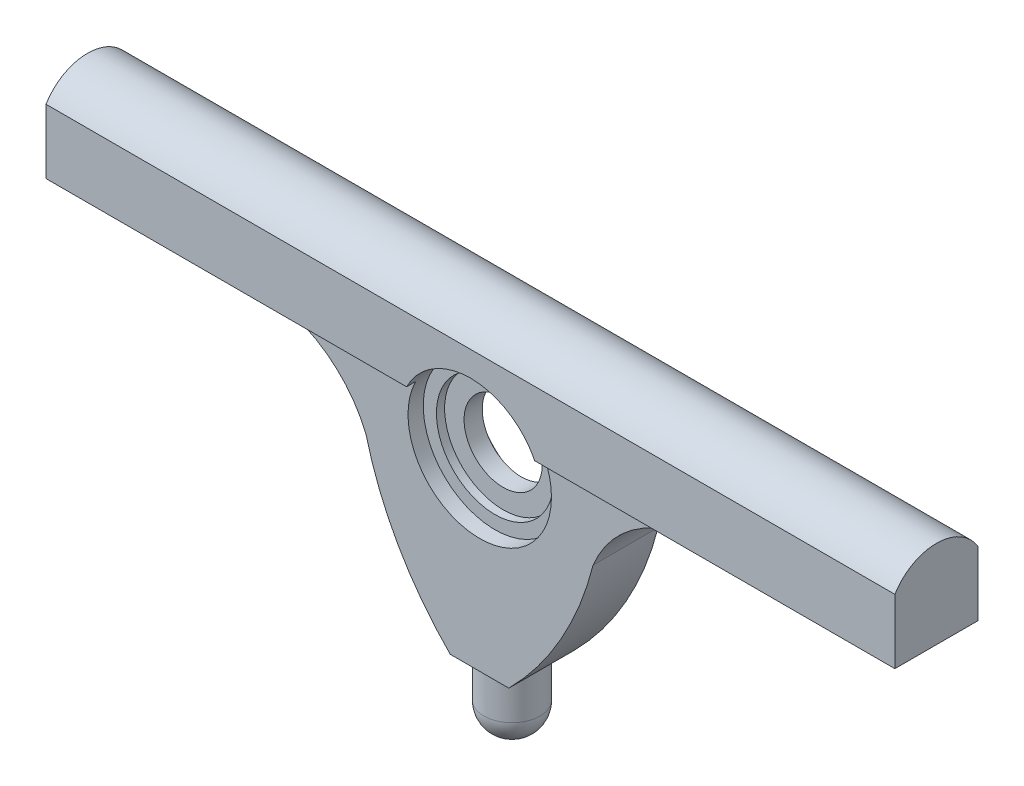
from build123d import *

# Parameters (mm, degrees)
BOSS_EXTRUDE1_DEPTH = 92.075
BOSS_EXTRUDE2_DEPTH = 7.0485


with BuildPart() as part:
    # Sketch1 → Boss-Extrude1 (new, symmetric)
    with BuildSketch(Plane(origin=(0, 0, 0), x_dir=(0, 0, -1), z_dir=(1, 0, 0))):
        with BuildLine():
            Line((-9.017, -6.985), (9.017, -6.985))
            Line((9.017, -6.985), (9.017, 6.985))
            ThreePointArc((9.017, 6.985), (0, 12.065), (-9.017, 6.985))
            Line((-9.017, 6.985), (-9.017, -6.985))
        make_face()
    extrude(amount=BOSS_EXTRUDE1_DEPTH, both=True)

    # 3DSketch1 → Boss-Extrude2 (add, symmetric)
    with BuildSketch(Plane(origin=(6.35, -54.483, 0), x_dir=(-0.707809670892054, 0.7064031920876931, 0), z_dir=(0, 0, -1))):
        with BuildLine():
            Line((0, 0), (8.98918282, -8.97132054))
            ThreePointArc((8.98918282, -8.97132054), (27.524857468, -6.428824004), (44.720760252, 0.942502247))
            ThreePointArc((44.720760252, 0.942502247), (56.955852786, 2.786694427), (68.610551817, -1.368606356))
            Line((68.610551817, -1.368606356), (7.484108639, 59.636373313))
            ThreePointArc((7.484108639, 59.636373313), (11.662583103, 47.989962481), (9.842730909, 35.751225941))
            ThreePointArc((9.842730909, 35.751225941), (2.50562293, 18.54069516), (0, 0))
        make_face()
    extrude(amount=BOSS_EXTRUDE2_DEPTH, both=True)

    # Sketch8 → Revolve2 (revolve)
    with BuildSketch(Plane.XY):
        with BuildLine():
            Line((0, -69.469), (0, -54.483))
            Line((0, -54.483), (6.096, -54.483))
            Line((6.096, -54.483), (6.096, -63.373))
            ThreePointArc((6.096, -63.373), (4.310522938, -67.683522938), (0, -69.469))
        make_face()
    revolve(axis=Axis((0, -47.134198832, 0), (0, -1, 0)))

    # Sketch10 → Cut-Revolve1 (revolve, cut)
    with BuildSketch(Plane(origin=(0, -13.977260066, 0), x_dir=(-1, 0, 0), z_dir=(0, -1, 0))):
        Polygon((-0.050623963, -9.017), (-0.050623963, 9.017), (-15.608123963, 9.017), (-15.608123963, 3.7465), (-12.750623963, 3.7465), (-12.750623963, 1.9685), (-8.534223963, 1.9685), (-8.534223963, -1.9685), (-12.750623963, -1.9685), (-12.750623963, -3.7465), (-15.608123963, -3.7465), (-15.608123963, -9.017), align=None)
    revolve(axis=Axis((0.050623963, -13.977260066, 55.769949285), (0, 0, -1)), mode=Mode.SUBTRACT)


solid = part.part
